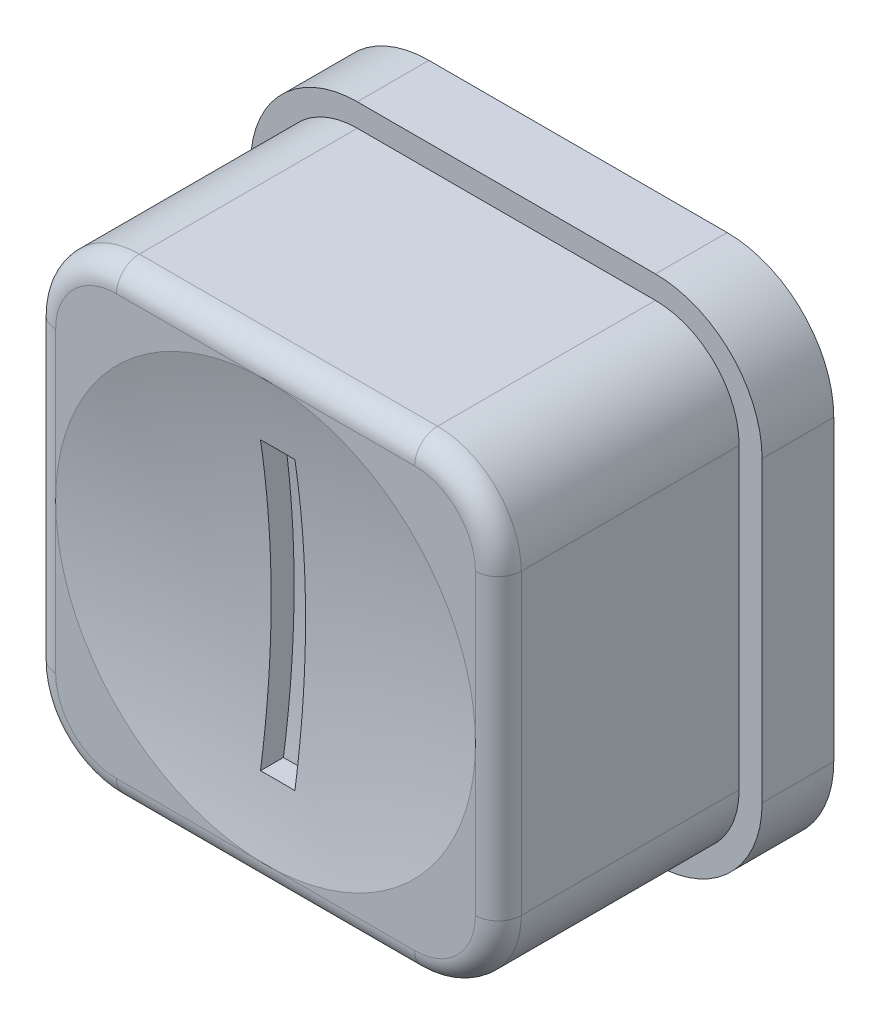
from build123d import *

# Parameters (mm, degrees)
BOSS_EXTRUDE1_DEPTH              = 5.334
FILLET1_R                        = 0.508
BOSS_EXTRUDE2_DEPTH              = 1.5875
F_56_0_0465_DIAMETER_HOLE1_D     = 1.1811
F_56_0_0465_DIAMETER_HOLE1_DEPTH = 5.08
CUT_EXTRUDE3_REACH               = 13.094
CUT_EXTRUDE3_START_RADIUS        = 21.519514579
CUT_EXTRUDE3_END_RADIUS          = 21.519514579
SKETCH9_W                        = 0.762
SKETCH9_H                        = 6.35


with BuildPart() as part:
    # Sketch1 → Boss-Extrude1 (new body)
    with BuildSketch(Plane.XY):
        with BuildLine():
            Line((3.301999954, 5.156199954), (-3.301999954, 5.156199954))
            ThreePointArc((-3.301999954, 5.156199954), (-4.613117348, 4.613117348), (-5.156199954, 3.301999954))
            Line((-5.156199954, 3.301999954), (-5.156199954, -3.301999954))
            ThreePointArc((-5.156199954, -3.301999954), (-4.613117348, -4.613117348), (-3.301999954, -5.156199954))
            Line((-3.301999954, -5.156199954), (3.301999954, -5.156199954))
            ThreePointArc((3.301999954, -5.156199954), (4.613117348, -4.613117348), (5.156199954, -3.301999954))
            Line((5.156199954, -3.301999954), (5.156199954, 3.301999954))
            ThreePointArc((5.156199954, 3.301999954), (4.613117348, 4.613117348), (3.301999954, 5.156199954))
        make_face()
    extrude(amount=-BOSS_EXTRUDE1_DEPTH)

    # Fillet1
    fillet1_edges = [part.edges().sort_by_distance(p)[0] for p in [
        (0, 5.156199954, 0),
        (4.613117348, 4.613117348, 0),
        (5.156199954, 0, 0),
        (4.613117348, -4.613117348, 0),
        (0, -5.156199954, 0),
        (-4.613117348, -4.613117348, 0),
        (-5.156199954, 0, 0),
        (-4.613117348, 4.613117348, 0),
    ]]
    fillet(fillet1_edges, radius=FILLET1_R)

    # Sketch4 → Boss-Extrude2 (add)
    with BuildSketch(Plane(origin=(0, 0, -5.334), x_dir=(-1, 0, 0), z_dir=(0, 0, -1))):
        with BuildLine():
            Line((-5.664199954, 3.301999954), (-5.664199954, -3.301999954))
            ThreePointArc((-5.664199954, -3.301999954), (-4.972327592, -4.972327592), (-3.301999954, -5.664199954))
            Line((-3.301999954, -5.664199954), (3.301999954, -5.664199954))
            ThreePointArc((3.301999954, -5.664199954), (4.972327592, -4.972327592), (5.664199954, -3.301999954))
            Line((5.664199954, -3.301999954), (5.664199954, 3.301999954))
            ThreePointArc((5.664199954, 3.301999954), (4.972327592, 4.972327592), (3.301999954, 5.664199954))
            Line((3.301999954, 5.664199954), (-3.301999954, 5.664199954))
            ThreePointArc((-3.301999954, 5.664199954), (-4.972327592, 4.972327592), (-5.664199954, 3.301999954))
        make_face()
    extrude(amount=BOSS_EXTRUDE2_DEPTH)

    # #56 (0.0465) Diameter Hole1
    with Locations(Plane(origin=(0, 0, -6.9215), x_dir=(-1, 0, 0), z_dir=(0, 0, -1))):
        with Locations((0, 0)):
            Hole(F_56_0_0465_DIAMETER_HOLE1_D / 2, depth=F_56_0_0465_DIAMETER_HOLE1_DEPTH)

    # Sketch8 → Cut-Revolve1 (revolve, cut)
    with BuildSketch(Plane(origin=(0, 0, 0), x_dir=(0, 0, -1), z_dir=(1, 0, 0)), mode=Mode.PRIVATE) as cut_revolve1_sk:
        with BuildLine():
            Line((0, 4.648199954), (0, 0))
            Line((0, 0), (0.508, 0))
            ThreePointArc((0.508, 0), (0.380623019, 2.337938558), (0, 4.648199954))
        make_face()
    revolve(cut_revolve1_sk.sketch.rotate(Axis((0, 0, -0.508), (0, 0, 1)), 90), axis=Axis((0, 0, -0.508), (0, 0, 1)), mode=Mode.SUBTRACT)

    # Cut-Extrude3: from a sphere face, 13.094 long prism both ways, kept between that surface and its translate by the depth
    cut_extrude3_start = Location((0, 0, 21.011514579)) * Sphere(CUT_EXTRUDE3_START_RADIUS, mode=Mode.PRIVATE)
    cut_extrude3_end = Location((0, 0, 20.503514579)) * Sphere(CUT_EXTRUDE3_END_RADIUS, mode=Mode.PRIVATE)
    # Sketch9 → Cut-Extrude3 (cut, from a surface)
    with BuildSketch(Plane.XY, mode=Mode.PRIVATE) as cut_extrude3_sk1:
        Rectangle(SKETCH9_W, SKETCH9_H)
    cut_extrude3_tool1 = extrude(cut_extrude3_sk1.sketch, amount=CUT_EXTRUDE3_REACH, both=True, mode=Mode.PRIVATE)
    add(((cut_extrude3_tool1 - cut_extrude3_start) & cut_extrude3_end).solids().sort_by_distance((0, 0, -0.52308))[0], mode=Mode.SUBTRACT)


solid = part.part
